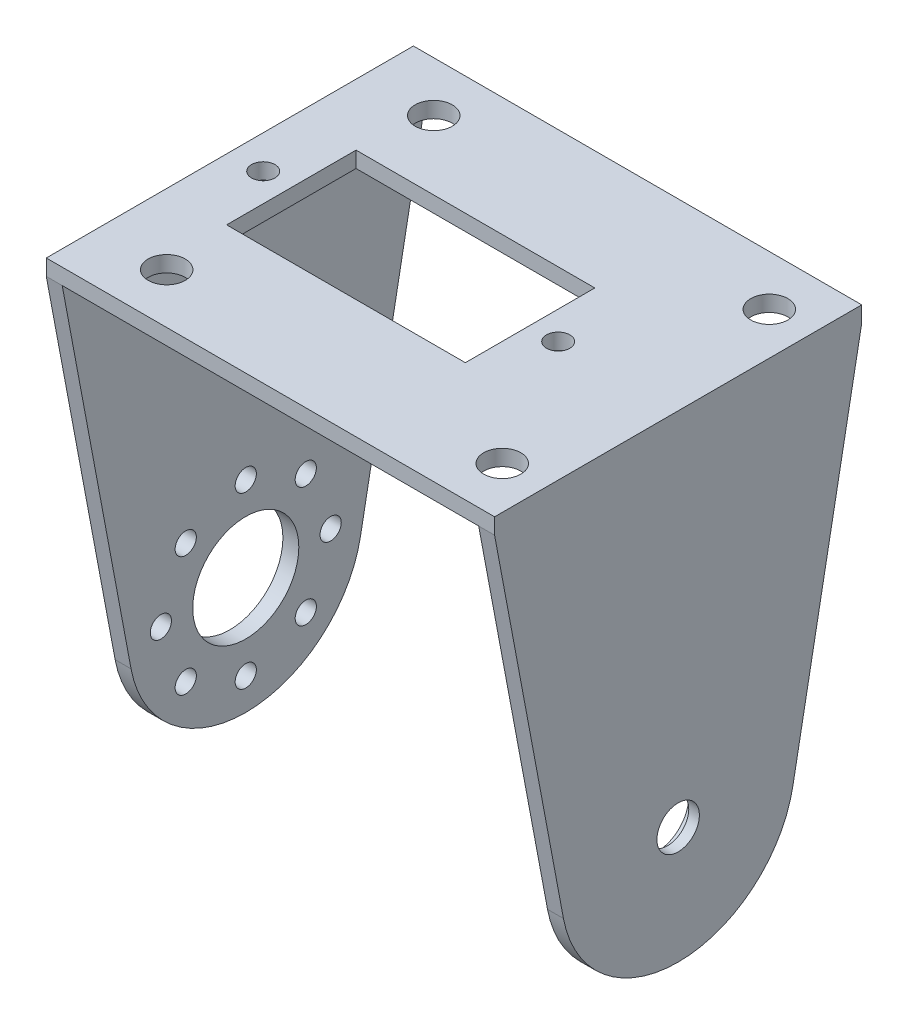
from build123d import *

# Parameters (mm, degrees)
SKETCH2_W           = 34.6
SKETCH2_H           = 1.5
SKETCH2_R           = 11
SKETCH2_R_2         = 1
SKETCH2_R_3         = 5
BOSS_EXTRUDE1_DEPTH = 1.5
SKETCH2_3_W         = 34.6
SKETCH2_3_H         = 1.5
BOSS_EXTRUDE2_DEPTH = 40.75
BOSS_EXTRUDE3_START = 40.75
SKETCH2_6_W         = 34.6
SKETCH2_6_H         = 1.5
SKETCH2_6_R         = 11
SKETCH2_6_R_2       = 1
SKETCH2_6_R_3       = 5
SKETCH2_6_R_4       = 4
SKETCH2_6_R_5       = 3
BOSS_EXTRUDE3_DEPTH = 1.5
SKETCH3_R           = 1.1
SKETCH3_R_2         = 1.75
SKETCH3_W           = 22.5
SKETCH3_H           = 12.2
CUT_EXTRUDE1_DEPTH  = 46
BOSS_EXTRUDE4_START = 40.75
SKETCH2_7_R         = 4
SKETCH2_7_R_2       = 3
BOSS_EXTRUDE4_DEPTH = 0.5
SKETCH4_R           = 3
SKETCH4_R_2         = 2
BOSS_EXTRUDE5_DEPTH = 1


with BuildPart() as part:
    # Sketch2 → Boss-Extrude1 (new body)
    with BuildSketch(Plane(origin=(0, 0, 0), x_dir=(0, 0, -1), z_dir=(1, 0, 0))):
        with BuildLine():
            Line((17.3, 32.5), (-17.3, 32.5))
            Line((-17.3, 32.5), (-10.810767407, -2.031577728))
            ThreePointArc((-10.810767407, -2.031577728), (-1.020185895, 10.952589682), (11, 0))
            ThreePointArc((11, 0), (10.952589682, -1.020185895), (10.810767407, -2.031577728))
            Line((10.810767407, -2.031577728), (17.3, 32.5))
        make_face()
        with Locations((0, 33.25)):
            Rectangle(SKETCH2_W, SKETCH2_H)
        Circle(SKETCH2_R)
        with Locations((-5.656854249, 5.656854249)):
            Circle(SKETCH2_R_2, mode=Mode.SUBTRACT)
        with Locations((-8, 0)):
            Circle(SKETCH2_R_2, mode=Mode.SUBTRACT)
        with Locations((-5.656854249, -5.656854249)):
            Circle(SKETCH2_R_2, mode=Mode.SUBTRACT)
        with Locations((0, -8)):
            Circle(SKETCH2_R_2, mode=Mode.SUBTRACT)
        with Locations((5.656854249, -5.656854249)):
            Circle(SKETCH2_R_2, mode=Mode.SUBTRACT)
        with Locations((8, 0)):
            Circle(SKETCH2_R_2, mode=Mode.SUBTRACT)
        with Locations((5.656854249, 5.656854249)):
            Circle(SKETCH2_R_2, mode=Mode.SUBTRACT)
        with Locations((0, 8)):
            Circle(SKETCH2_R_2, mode=Mode.SUBTRACT)
        Circle(SKETCH2_R_3, mode=Mode.SUBTRACT)
    extrude(amount=BOSS_EXTRUDE1_DEPTH)

    # Sketch2_3 → Boss-Extrude2 (add)
    with BuildSketch(Plane(origin=(0, 0, 0), x_dir=(0, 0, -1), z_dir=(1, 0, 0))):
        with Locations((0, 33.25)):
            Rectangle(SKETCH2_3_W, SKETCH2_3_H)
    extrude(amount=BOSS_EXTRUDE2_DEPTH)

    # Sketch2_6 → Boss-Extrude3 (add)
    with BuildSketch(Plane(origin=(0, 0, 0), x_dir=(0, 0, -1), z_dir=(1, 0, 0)).offset(BOSS_EXTRUDE3_START)):
        with Locations((0, 33.25)):
            Rectangle(SKETCH2_6_W, SKETCH2_6_H)
        with BuildLine():
            Line((17.3, 32.5), (-17.3, 32.5))
            Line((-17.3, 32.5), (-10.810767407, -2.031577728))
            ThreePointArc((-10.810767407, -2.031577728), (-1.020185895, 10.952589682), (11, 0))
            ThreePointArc((11, 0), (10.952589682, -1.020185895), (10.810767407, -2.031577728))
            Line((10.810767407, -2.031577728), (17.3, 32.5))
        make_face()
        Circle(SKETCH2_6_R)
        with Locations((-5.656854249, 5.656854249)):
            Circle(SKETCH2_6_R_2, mode=Mode.SUBTRACT)
        with Locations((-8, 0)):
            Circle(SKETCH2_6_R_2, mode=Mode.SUBTRACT)
        with Locations((-5.656854249, -5.656854249)):
            Circle(SKETCH2_6_R_2, mode=Mode.SUBTRACT)
        with Locations((0, -8)):
            Circle(SKETCH2_6_R_2, mode=Mode.SUBTRACT)
        with Locations((5.656854249, -5.656854249)):
            Circle(SKETCH2_6_R_2, mode=Mode.SUBTRACT)
        with Locations((8, 0)):
            Circle(SKETCH2_6_R_2, mode=Mode.SUBTRACT)
        with Locations((5.656854249, 5.656854249)):
            Circle(SKETCH2_6_R_2, mode=Mode.SUBTRACT)
        with Locations((0, 8)):
            Circle(SKETCH2_6_R_2, mode=Mode.SUBTRACT)
        Circle(SKETCH2_6_R_3, mode=Mode.SUBTRACT)
        with Locations((0, 8)):
            Circle(SKETCH2_6_R_2)
        with Locations((-5.656854249, 5.656854249)):
            Circle(SKETCH2_6_R_2)
        with Locations((-8, 0)):
            Circle(SKETCH2_6_R_2)
        with Locations((-5.656854249, -5.656854249)):
            Circle(SKETCH2_6_R_2)
        with Locations((0, -8)):
            Circle(SKETCH2_6_R_2)
        with Locations((5.656854249, -5.656854249)):
            Circle(SKETCH2_6_R_2)
        with Locations((8, 0)):
            Circle(SKETCH2_6_R_2)
        with Locations((5.656854249, 5.656854249)):
            Circle(SKETCH2_6_R_2)
        Circle(SKETCH2_6_R_3)
        Circle(SKETCH2_6_R_4, mode=Mode.SUBTRACT)
        Circle(SKETCH2_6_R_4)
        Circle(SKETCH2_6_R_5, mode=Mode.SUBTRACT)
    extrude(amount=BOSS_EXTRUDE3_DEPTH)

    # Sketch3 → Cut-Extrude1 (cut, through all)
    with BuildSketch(Plane(origin=(0, 34, 0), x_dir=(1, 0, 0), z_dir=(0, 1, 0))):
        with Locations((30.945, 0)):
            Circle(SKETCH3_R)
        with Locations((3.145, 0)):
            Circle(SKETCH3_R)
        with Locations((6.63, 12.583801515)):
            Circle(SKETCH3_R_2)
        with Locations((38.257478, 12.583801515)):
            Circle(SKETCH3_R_2)
        with Locations((38.257478, -12.583801515)):
            Circle(SKETCH3_R_2)
        with Locations((6.63, -12.583801515)):
            Circle(SKETCH3_R_2)
        with Locations((17.045, 0)):
            Rectangle(SKETCH3_W, SKETCH3_H)
    extrude(amount=-CUT_EXTRUDE1_DEPTH, mode=Mode.SUBTRACT)

    # Sketch2_7 → Boss-Extrude4 (add)
    with BuildSketch(Plane(origin=(0, 0, 0), x_dir=(0, 0, -1), z_dir=(1, 0, 0)).offset(BOSS_EXTRUDE4_START)):
        Circle(SKETCH2_7_R)
        Circle(SKETCH2_7_R_2, mode=Mode.SUBTRACT)
    extrude(amount=-BOSS_EXTRUDE4_DEPTH)

    # Sketch4 → Boss-Extrude5 (add)
    with BuildSketch(Plane(origin=(42.25, 0, 0), x_dir=(0, 0, -1), z_dir=(1, 0, 0))):
        Circle(SKETCH4_R)
        Circle(SKETCH4_R_2, mode=Mode.SUBTRACT)
    extrude(amount=-BOSS_EXTRUDE5_DEPTH)


solid = part.part
